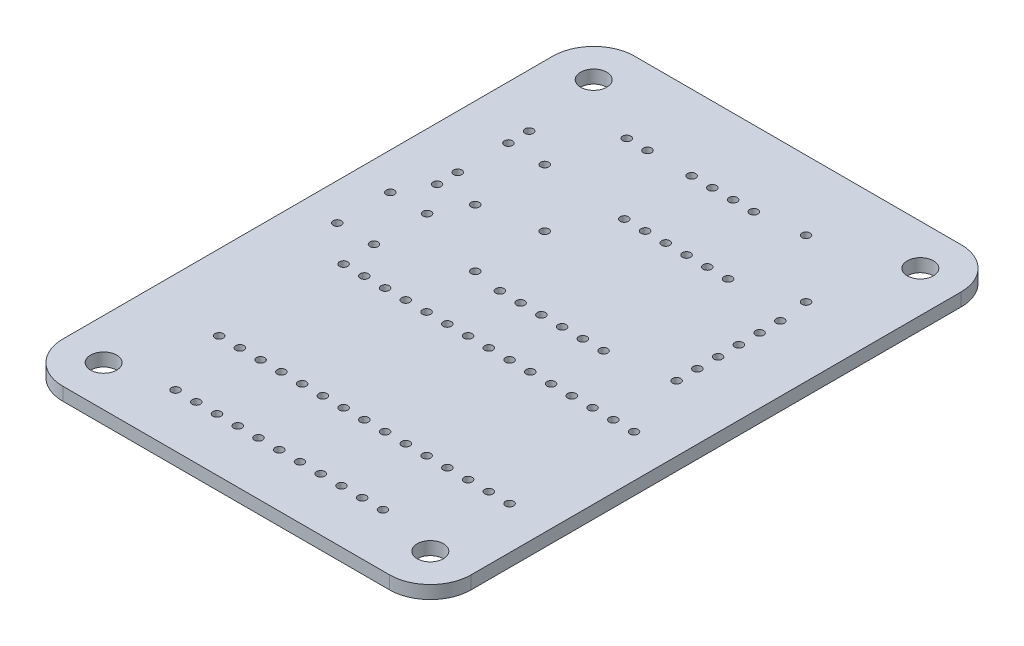
from build123d import *

# Parameters (mm, degrees)
SKETCH1_W           = 50
SKETCH1_H           = 70
BOSS_EXTRUDE1_DEPTH = 1.6
FILLET2_R           = 5
SKETCH2_R           = 1.6
CUT_EXTRUDE1_DEPTH  = 1.6
SKETCH3_R           = 0.5
CUT_EXTRUDE2_DEPTH  = 1.6


with BuildPart() as part:
    # Sketch1 → Boss-Extrude1 (new body)
    with BuildSketch(Plane(origin=(0, 0, 0), x_dir=(1, 0, 0), z_dir=(0, 1, 0))):
        Rectangle(SKETCH1_W, SKETCH1_H)
    extrude(amount=BOSS_EXTRUDE1_DEPTH)

    # Fillet2
    fillet2_edges = [part.edges().sort_by_distance(p)[0] for p in [
        (25, 0.8, 35),
        (-25, 0.8, 35),
        (-25, 0.8, -35),
        (25, 0.8, -35),
    ]]
    fillet(fillet2_edges, radius=FILLET2_R)

    # Sketch2 → Cut-Extrude1 (cut)
    with BuildSketch(Plane(origin=(0, 1.6, 0), x_dir=(1, 0, 0), z_dir=(0, 1, 0))):
        with Locations((-20, 30)):
            Circle(SKETCH2_R)
        with Locations((20, 30)):
            Circle(SKETCH2_R)
        with Locations((20, -30)):
            Circle(SKETCH2_R)
        with Locations((-20, -30)):
            Circle(SKETCH2_R)
    extrude(amount=-CUT_EXTRUDE1_DEPTH, mode=Mode.SUBTRACT)

    # Sketch3 → Cut-Extrude2 (cut)
    with BuildSketch(Plane(origin=(0, 1.6, 0), x_dir=(1, 0, 0), z_dir=(0, 1, 0))):
        with Locations((-3.81, 25.8)):
            Circle(SKETCH3_R)
        with Locations((-1.27, 25.8)):
            Circle(SKETCH3_R)
        with Locations((1.27, 25.8)):
            Circle(SKETCH3_R)
        with Locations((3.81, 25.8)):
            Circle(SKETCH3_R)
        with Locations((-11.75, 25.8)):
            Circle(SKETCH3_R)
        with Locations((-9.21, 25.8)):
            Circle(SKETCH3_R)
        with Locations((-15.76, -20.1)):
            Circle(SKETCH3_R)
        with Locations((-13.22, -20.1)):
            Circle(SKETCH3_R)
        with Locations((-10.68, -20.1)):
            Circle(SKETCH3_R)
        with Locations((-8.14, -20.1)):
            Circle(SKETCH3_R)
        with Locations((-5.6, -20.1)):
            Circle(SKETCH3_R)
        with Locations((-3.06, -20.1)):
            Circle(SKETCH3_R)
        with Locations((-0.52, -20.1)):
            Circle(SKETCH3_R)
        with Locations((2.02, -20.1)):
            Circle(SKETCH3_R)
        with Locations((4.56, -20.1)):
            Circle(SKETCH3_R)
        with Locations((7.1, -20.1)):
            Circle(SKETCH3_R)
        with Locations((9.64, -20.1)):
            Circle(SKETCH3_R)
        with Locations((12.18, -20.1)):
            Circle(SKETCH3_R)
        with Locations((14.72, -20.1)):
            Circle(SKETCH3_R)
        with Locations((17.26, -20.1)):
            Circle(SKETCH3_R)
        with Locations((19.8, -20.1)):
            Circle(SKETCH3_R)
        with Locations((-15.76, -4.86)):
            Circle(SKETCH3_R)
        with Locations((-13.22, -4.86)):
            Circle(SKETCH3_R)
        with Locations((-10.68, -4.86)):
            Circle(SKETCH3_R)
        with Locations((-8.14, -4.86)):
            Circle(SKETCH3_R)
        with Locations((-5.6, -4.86)):
            Circle(SKETCH3_R)
        with Locations((-3.06, -4.86)):
            Circle(SKETCH3_R)
        with Locations((-0.52, -4.86)):
            Circle(SKETCH3_R)
        with Locations((2.02, -4.86)):
            Circle(SKETCH3_R)
        with Locations((4.56, -4.86)):
            Circle(SKETCH3_R)
        with Locations((7.1, -4.86)):
            Circle(SKETCH3_R)
        with Locations((9.64, -4.86)):
            Circle(SKETCH3_R)
        with Locations((12.18, -4.86)):
            Circle(SKETCH3_R)
        with Locations((14.72, -4.86)):
            Circle(SKETCH3_R)
        with Locations((17.26, -4.86)):
            Circle(SKETCH3_R)
        with Locations((19.8, -4.86)):
            Circle(SKETCH3_R)
        with Locations((-3.35, 1.86)):
            Circle(SKETCH3_R)
        with Locations((-0.81, 1.86)):
            Circle(SKETCH3_R)
        with Locations((1.73, 1.86)):
            Circle(SKETCH3_R)
        with Locations((4.27, 1.86)):
            Circle(SKETCH3_R)
        with Locations((6.81, 1.86)):
            Circle(SKETCH3_R)
        with Locations((9.35, 1.86)):
            Circle(SKETCH3_R)
        with Locations((-3.35, 17.1)):
            Circle(SKETCH3_R)
        with Locations((-0.81, 17.1)):
            Circle(SKETCH3_R)
        with Locations((1.73, 17.1)):
            Circle(SKETCH3_R)
        with Locations((4.27, 17.1)):
            Circle(SKETCH3_R)
        with Locations((6.81, 17.1)):
            Circle(SKETCH3_R)
        with Locations((9.35, 17.1)):
            Circle(SKETCH3_R)
        with Locations((-12.7, -28.5)):
            Circle(SKETCH3_R)
        with Locations((-10.16, -28.5)):
            Circle(SKETCH3_R)
        with Locations((-7.62, -28.5)):
            Circle(SKETCH3_R)
        with Locations((-5.08, -28.5)):
            Circle(SKETCH3_R)
        with Locations((-2.54, -28.5)):
            Circle(SKETCH3_R)
        with Locations((0, -28.5)):
            Circle(SKETCH3_R)
        with Locations((2.54, -28.5)):
            Circle(SKETCH3_R)
        with Locations((5.08, -28.5)):
            Circle(SKETCH3_R)
        with Locations((7.62, -28.5)):
            Circle(SKETCH3_R)
        with Locations((10.16, -28.5)):
            Circle(SKETCH3_R)
        with Locations((12.7, -28.5)):
            Circle(SKETCH3_R)
        with Locations((17, 15.85)):
            Circle(SKETCH3_R)
        with Locations((17, 13.31)):
            Circle(SKETCH3_R)
        with Locations((17, 10.77)):
            Circle(SKETCH3_R)
        with Locations((17, 3.15)):
            Circle(SKETCH3_R)
        with Locations((17, 5.69)):
            Circle(SKETCH3_R)
        with Locations((17, 8.23)):
            Circle(SKETCH3_R)
        with Locations((-18.5, 20.6)):
            Circle(SKETCH3_R)
        with Locations((-18.5, 18.06)):
            Circle(SKETCH3_R)
        with Locations((-18.5, 11.86)):
            Circle(SKETCH3_R)
        with Locations((-18.5, 9.32)):
            Circle(SKETCH3_R)
        with Locations((-16, 5.6)):
            Circle(SKETCH3_R)
        with Locations((-16, -0.9)):
            Circle(SKETCH3_R)
        with Locations((-20.5, -0.9)):
            Circle(SKETCH3_R)
        with Locations((-20.5, 5.6)):
            Circle(SKETCH3_R)
        with Locations((9.5, 26.5)):
            Circle(SKETCH3_R)
        with Locations((16.571067812, 19.428932188)):
            Circle(SKETCH3_R)
        with Locations((-6.928932188, 10.928932188)):
            Circle(SKETCH3_R)
        with Locations((-14, 18)):
            Circle(SKETCH3_R)
        with Locations((-14, 9.5)):
            Circle(SKETCH3_R)
        with Locations((-6.928932188, 2.428932188)):
            Circle(SKETCH3_R)
    extrude(amount=-CUT_EXTRUDE2_DEPTH, mode=Mode.SUBTRACT)


solid = part.part
